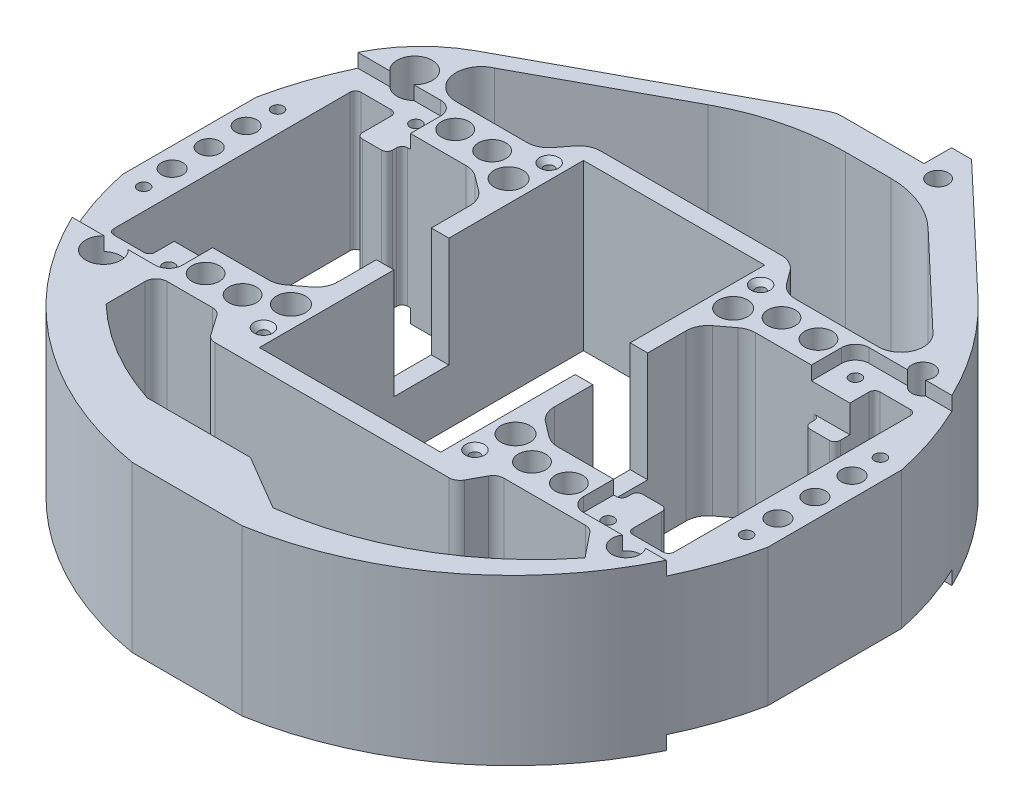
from build123d import *

# Parameters (mm, degrees)
SKETCH1_R             = 2.356484411
SKETCH1_R_2           = 3.356538595
SKETCH1_R_3           = 3.175
SKETCH1_R_4           = 4.064709562
SKETCH1_R_5           = 2.555437721
SKETCH1_R_6           = 3.242334338
SKETCH1_R_7           = 2.462755239
BOSS_EXTRUDE1_DEPTH   = 38.1
SKETCH2_W             = 4.064
SKETCH2_H             = 12.7
CUT_EXTRUDE1_DEPTH    = 25.4
CUT_EXTRUDE2_DEPTH    = 3.175
SKETCH4_R             = 1.35255
CUT_EXTRUDE3_DEPTH    = 6.35
SKETCH5_W             = 15.815775359
SKETCH5_H             = 5.307603771
CUT_EXTRUDE4_DEPTH    = 6.35
SKETCH6_R             = 1.1303
CUT_EXTRUDE5_DEPTH    = 12.7
CHAMFER1_SIZE         = 1.19507
CHAMFER1_SIZE2        = 1.038858502
CHAMFER2_SIZE         = 1.19507
CHAMFER2_SIZE2        = 1.038858502
CHAMFER2_PART_2_SIZE  = 1.19507
CHAMFER2_PART_2_SIZE2 = 1.038858502
CHAMFER2_PART_3_SIZE  = 1.19507
CHAMFER2_PART_3_SIZE2 = 1.038858502
CHAMFER2_PART_4_SIZE  = 1.19507
CHAMFER2_PART_4_SIZE2 = 1.038858502
SKETCH7_W             = 19.05
SKETCH7_H             = 15.875
CUT_EXTRUDE6_DEPTH    = 0.79375


with BuildPart() as part:
    # Sketch1 → Boss-Extrude1 (new body)
    with BuildSketch(Plane(origin=(0, 0, 0), x_dir=(1, 0, 0), z_dir=(0, 1, 0))):
        with BuildLine():
            Line((-74.6125, 15.473036022), (-74.6125, -15.473036022))
            ThreePointArc((-74.6125, -15.473036022), (-52.874683743, -54.86991725), (-12.7, -75.134213245))
            Line((-12.7, -75.134213245), (12.7, -75.134213245))
            ThreePointArc((12.7, -75.134213245), (52.874683743, -54.86991725), (74.6125, -15.473036022))
            Line((74.6125, -15.473036022), (74.6125, 15.473036022))
            ThreePointArc((74.6125, 15.473036022), (66.568680107, 37.081677804), (52.429845716, 55.295128883))
            Line((52.429845716, 55.295128883), (23.6855, 82.55))
            Line((23.6855, 82.55), (19.05, 82.55))
            Line((19.05, 82.55), (19.05, 76.99375))
            Line((19.05, 76.99375), (0, 76.99375))
            Line((0, 76.99375), (0, 76.2))
            ThreePointArc((0, 76.2), (-1.309576606, 76.036760248), (-2.539006662, 75.557031324))
            Line((-2.539006662, 75.557031324), (-55.150410299, 47.084918442))
            ThreePointArc((-55.150410299, 47.084918442), (-63.168001103, 40.936392006), (-68.874977996, 32.598733198))
            ThreePointArc((-68.874977996, 32.598733198), (-72.252933929, 24.206477205), (-74.6125, 15.473036022))
        make_face()
        with Locations((23.6855, 74.812542953)):
            Circle(SKETCH1_R, mode=Mode.SUBTRACT)
        with Locations((-25.953983408, 25.159074147)):
            Circle(SKETCH1_R_2, mode=Mode.SUBTRACT)
        with Locations((-41.987680119, 28.850105121)):
            Circle(SKETCH1_R_3, mode=Mode.SUBTRACT)
        with Locations((41.987680119, 28.850105121)):
            Circle(SKETCH1_R_3, mode=Mode.SUBTRACT)
        with Locations((-41.987680119, -28.850105121)):
            Circle(SKETCH1_R_3, mode=Mode.SUBTRACT)
        with Locations((41.987680119, -28.850105121)):
            Circle(SKETCH1_R_3, mode=Mode.SUBTRACT)
        with Locations((-33.451838253, 28.850105121)):
            Circle(SKETCH1_R_3, mode=Mode.SUBTRACT)
        with Locations((33.451838253, 28.850105121)):
            Circle(SKETCH1_R_3, mode=Mode.SUBTRACT)
        with Locations((-33.451838253, -28.850105121)):
            Circle(SKETCH1_R_3, mode=Mode.SUBTRACT)
        with Locations((33.451838253, -28.850105121)):
            Circle(SKETCH1_R_3, mode=Mode.SUBTRACT)
        with Locations((-58.499626731, 35.97459363)):
            Circle(SKETCH1_R_4, mode=Mode.SUBTRACT)
        with Locations((60.460006294, 34.52310187)):
            Circle(SKETCH1_R_5, mode=Mode.SUBTRACT)
        with Locations((-58.499626731, -35.97459363)):
            Circle(SKETCH1_R_4, mode=Mode.SUBTRACT)
        with Locations((61.236723994, -34.882223147)):
            Circle(SKETCH1_R_6, mode=Mode.SUBTRACT)
        with Locations((25.953983408, 25.159074147)):
            Circle(SKETCH1_R_2, mode=Mode.SUBTRACT)
        with Locations((25.953983408, -25.159074147)):
            Circle(SKETCH1_R_2, mode=Mode.SUBTRACT)
        with Locations((-25.953983408, -25.159074147)):
            Circle(SKETCH1_R_2, mode=Mode.SUBTRACT)
        with Locations((70.02564652, 8.562540674)):
            Circle(SKETCH1_R_7, mode=Mode.SUBTRACT)
        with Locations((-70.02564652, 8.562540674)):
            Circle(SKETCH1_R_7, mode=Mode.SUBTRACT)
        with Locations((70.02564652, -8.562540674)):
            Circle(SKETCH1_R_7, mode=Mode.SUBTRACT)
        with Locations((-70.02564652, -8.562540674)):
            Circle(SKETCH1_R_7, mode=Mode.SUBTRACT)
        with Locations((-70.02564652, 0)):
            Circle(SKETCH1_R_7, mode=Mode.SUBTRACT)
        with Locations((70.02564652, 0)):
            Circle(SKETCH1_R_7, mode=Mode.SUBTRACT)
        Polygon((20.955, 37.465), (-20.955, 37.465), (-20.955, 0), (-20.955, -37.465), (20.955, -37.465), (20.955, 0), align=None, mode=Mode.SUBTRACT)
        with BuildLine():
            Line((-53.975, 19.3675), (-49.53, 19.3675))
            ThreePointArc((-49.53, 19.3675), (-48.631974388, 19.739474388), (-48.26, 20.6375))
            Line((-48.26, 20.6375), (-48.26, 21.59))
            ThreePointArc((-48.26, 21.59), (-47.888025612, 22.488025612), (-46.99, 22.86))
            Line((-46.99, 22.86), (-33.451838253, 22.86))
            ThreePointArc((-33.451838253, 22.86), (-31.838145049, 22.596886364), (-30.391611171, 21.834800884))
            Line((-30.391611171, 21.834800884), (-27.038772918, 19.304356919))
            ThreePointArc((-27.038772918, 19.304356919), (-25.551893581, 17.514555641), (-25.019, 15.249556036))
            Line((-25.019, 15.249556036), (-25.019, 0))
            Line((-25.019, 0), (-25.019, -15.249556036))
            ThreePointArc((-25.019, -15.249556036), (-25.551893581, -17.514555641), (-27.038772918, -19.304356919))
            Line((-27.038772918, -19.304356919), (-30.391611171, -21.834800884))
            ThreePointArc((-30.391611171, -21.834800884), (-31.838145049, -22.596886364), (-33.451838253, -22.86))
            Line((-33.451838253, -22.86), (-46.99, -22.86))
            ThreePointArc((-46.99, -22.86), (-47.888025612, -22.488025612), (-48.26, -21.59))
            Line((-48.26, -21.59), (-48.26, -20.6375))
            ThreePointArc((-48.26, -20.6375), (-48.631974388, -19.739474388), (-49.53, -19.3675))
            Line((-49.53, -19.3675), (-53.975, -19.3675))
            ThreePointArc((-53.975, -19.3675), (-54.873025612, -19.739474388), (-55.245, -20.6375))
            Line((-55.245, -20.6375), (-55.245, -27.305))
            ThreePointArc((-55.245, -27.305), (-55.616974388, -28.203025612), (-56.515, -28.575))
            Line((-56.515, -28.575), (-63.5, -28.575))
            ThreePointArc((-63.5, -28.575), (-64.398025612, -28.203025612), (-64.77, -27.305))
            Line((-64.77, -27.305), (-64.77, 27.305))
            ThreePointArc((-64.77, 27.305), (-64.398025612, 28.203025612), (-63.5, 28.575))
            Line((-63.5, 28.575), (-56.515, 28.575))
            ThreePointArc((-56.515, 28.575), (-55.616974388, 28.203025612), (-55.245, 27.305))
            Line((-55.245, 27.305), (-55.245, 20.6375))
            ThreePointArc((-55.245, 20.6375), (-54.873025612, 19.739474388), (-53.975, 19.3675))
        make_face(mode=Mode.SUBTRACT)
        with BuildLine():
            Line((64.77, 27.305), (64.77, -27.305))
            ThreePointArc((64.77, -27.305), (64.398025612, -28.203025612), (63.5, -28.575))
            Line((63.5, -28.575), (56.515, -28.575))
            ThreePointArc((56.515, -28.575), (55.616974388, -28.203025612), (55.245, -27.305))
            Line((55.245, -27.305), (55.245, -20.6375))
            ThreePointArc((55.245, -20.6375), (54.873025612, -19.739474388), (53.975, -19.3675))
            Line((53.975, -19.3675), (49.53, -19.3675))
            ThreePointArc((49.53, -19.3675), (48.631974388, -19.739474388), (48.26, -20.6375))
            Line((48.26, -20.6375), (48.26, -21.59))
            ThreePointArc((48.26, -21.59), (47.888025612, -22.488025612), (46.99, -22.86))
            Line((46.99, -22.86), (33.451838253, -22.86))
            ThreePointArc((33.451838253, -22.86), (31.838145049, -22.596886364), (30.391611171, -21.834800884))
            Line((30.391611171, -21.834800884), (27.038772918, -19.304356919))
            ThreePointArc((27.038772918, -19.304356919), (25.551893581, -17.514555641), (25.019, -15.249556036))
            Line((25.019, -15.249556036), (25.019, 0))
            Line((25.019, 0), (25.019, 15.249556036))
            ThreePointArc((25.019, 15.249556036), (25.551893581, 17.514555641), (27.038772918, 19.304356919))
            Line((27.038772918, 19.304356919), (30.391611171, 21.834800884))
            ThreePointArc((30.391611171, 21.834800884), (31.838145049, 22.596886364), (33.451838253, 22.86))
            Line((33.451838253, 22.86), (46.99, 22.86))
            ThreePointArc((46.99, 22.86), (47.888025612, 22.488025612), (48.26, 21.59))
            Line((48.26, 21.59), (48.26, 20.6375))
            ThreePointArc((48.26, 20.6375), (48.631974388, 19.739474388), (49.53, 19.3675))
            Line((49.53, 19.3675), (53.975, 19.3675))
            ThreePointArc((53.975, 19.3675), (54.873025612, 19.739474388), (55.245, 20.6375))
            Line((55.245, 20.6375), (55.245, 27.305))
            ThreePointArc((55.245, 27.305), (55.616974388, 28.203025612), (56.515, 28.575))
            Line((56.515, 28.575), (63.5, 28.575))
            ThreePointArc((63.5, 28.575), (64.398025612, 28.203025612), (64.77, 27.305))
        make_face(mode=Mode.SUBTRACT)
        with BuildLine():
            Line((-20.845950883, 41.338131188), (0, 41.338131188))
            Line((0, 41.338131188), (20.910135118, 41.338131188))
            ThreePointArc((20.910135118, 41.338131188), (23.203410667, 40.791042753), (25.00273955, 39.267614359))
            Line((25.00273955, 39.267614359), (27.190928166, 36.29189065))
            ThreePointArc((27.190928166, 36.29189065), (28.990257049, 34.768462257), (31.283532598, 34.221373822))
            Line((31.283532598, 34.221373822), (50.455815119, 34.221373822))
            ThreePointArc((50.455815119, 34.221373822), (55.316788611, 37.516325014), (54.056495, 43.251952848))
            Line((54.056495, 43.251952848), (32.476102374, 63.71409262))
            ThreePointArc((32.476102374, 63.71409262), (25.857925946, 67.947781019), (18.142380695, 69.429245892))
            Line((18.142380695, 69.429245892), (7.650592912, 69.429245892))
            ThreePointArc((7.650592912, 69.429245892), (-5.443696115, 67.79703249), (-17.736610037, 63.000284321))
            Line((-17.736610037, 63.000284321), (-49.707341043, 45.69844101))
            ThreePointArc((-49.707341043, 45.69844101), (-53.151906064, 39.187793332), (-47.451536346, 34.52310187))
            Line((-47.451536346, 34.52310187), (-31.086999544, 34.52310187))
            ThreePointArc((-31.086999544, 34.52310187), (-28.840846685, 35.046656179), (-27.057679262, 36.509402133))
            Line((-27.057679262, 36.509402133), (-24.875271165, 39.351830925))
            ThreePointArc((-24.875271165, 39.351830925), (-23.092103742, 40.814576878), (-20.845950883, 41.338131188))
        make_face(mode=Mode.SUBTRACT)
        with BuildLine():
            Line((-23.854336738, -60.495536567), (0, -60.495536567))
            Line((0, -60.495536567), (12.7, -67.96894498))
            ThreePointArc((12.7, -67.96894498), (38.322472705, -59.497281046), (58.80689112, -41.928308409))
            Line((58.80689112, -41.928308409), (54.275996481, -36.293661738))
            ThreePointArc((54.275996481, -36.293661738), (53.394000982, -35.594661364), (52.296567671, -35.345346879))
            Line((52.296567671, -35.345346879), (33.457769344, -35.345346879))
            ThreePointArc((33.457769344, -35.345346879), (32.159314658, -35.702317921), (31.225829045, -36.672893786))
            Line((31.225829045, -36.672893786), (29.270713217, -40.271962344))
            ThreePointArc((29.270713217, -40.271962344), (28.337227604, -41.242538208), (27.038772918, -41.599509251))
            Line((27.038772918, -41.599509251), (-27.038772918, -41.599509251))
            ThreePointArc((-27.038772918, -41.599509251), (-28.216614381, -41.30990688), (-29.125868694, -40.507138769))
            Line((-29.125868694, -40.507138769), (-32.269685191, -35.97459363))
            ThreePointArc((-32.269685191, -35.97459363), (-33.178939505, -35.171825519), (-34.356780968, -34.882223147))
            Line((-34.356780968, -34.882223147), (-44.859278162, -34.882223147))
            ThreePointArc((-44.859278162, -34.882223147), (-46.655329386, -35.626171923), (-47.399278162, -37.422223147))
            Line((-47.399278162, -37.422223147), (-47.399278162, -46.454771748))
            ThreePointArc((-47.399278162, -46.454771748), (-36.419314032, -54.804107481), (-23.854336738, -60.495536567))
        make_face(mode=Mode.SUBTRACT)
    extrude(amount=BOSS_EXTRUDE1_DEPTH)

    # Sketch2 → Cut-Extrude1 (cut)
    with BuildSketch(Plane(origin=(0, 38.1, 0), x_dir=(1, 0, 0), z_dir=(0, 1, 0))):
        with Locations((-22.987, 0)):
            Rectangle(SKETCH2_W, SKETCH2_H)
        with Locations((22.987, 0)):
            Rectangle(SKETCH2_W, SKETCH2_H)
    extrude(amount=-CUT_EXTRUDE1_DEPTH, mode=Mode.SUBTRACT)

    # Sketch3 → Cut-Extrude2 (cut)
    with BuildSketch(Plane(origin=(0, 38.1, 0), x_dir=(1, 0, 0), z_dir=(0, 1, 0))):
        with BuildLine():
            Line((-49.53, 33.02), (-80.011418761, 33.02))
            Line((-80.011418761, 33.02), (-80.011418761, -33.02))
            Line((-80.011418761, -33.02), (-49.53, -33.02))
            ThreePointArc((-49.53, -33.02), (-47.28493597, -32.09006403), (-46.355, -29.845))
            Line((-46.355, -29.845), (-46.355, 29.845))
            ThreePointArc((-46.355, 29.845), (-47.28493597, 32.09006403), (-49.53, 33.02))
        make_face()
        with BuildLine():
            Line((80.011418761, 33.02), (80.011418761, -33.02))
            Line((80.011418761, -33.02), (49.53, -33.02))
            ThreePointArc((49.53, -33.02), (47.28493597, -32.09006403), (46.355, -29.845))
            Line((46.355, -29.845), (46.355, 29.845))
            ThreePointArc((46.355, 29.845), (47.28493597, 32.09006403), (49.53, 33.02))
            Line((49.53, 33.02), (80.011418761, 33.02))
        make_face()
    cut_extrude2 = extrude(amount=-CUT_EXTRUDE2_DEPTH, mode=Mode.SUBTRACT)

    # Sketch4 → Cut-Extrude3 (cut)
    with BuildSketch(Plane(origin=(0, 34.925, 0), x_dir=(1, 0, 0), z_dir=(0, 1, 0))):
        with Locations((-50.8, 28.575)):
            Circle(SKETCH4_R)
        with Locations((-69.69125, 15.473036022)):
            Circle(SKETCH4_R)
        with Locations((69.69125, 15.473036022)):
            Circle(SKETCH4_R)
        with Locations((50.8, 28.575)):
            Circle(SKETCH4_R)
        with Locations((50.8, -28.575)):
            Circle(SKETCH4_R)
        with Locations((69.69125, -15.473036022)):
            Circle(SKETCH4_R)
        with Locations((-69.69125, -15.473036022)):
            Circle(SKETCH4_R)
        with Locations((-50.8, -28.575)):
            Circle(SKETCH4_R)
    cut_extrude3 = extrude(amount=-CUT_EXTRUDE3_DEPTH, mode=Mode.SUBTRACT)

    # Mirror1: Cut-Extrude2, Cut-Extrude3 across plane
    add(cut_extrude2.mirror(Plane.ZX.offset(19.05)), mode=Mode.SUBTRACT)
    add(cut_extrude3.mirror(Plane.ZX.offset(19.05)), mode=Mode.SUBTRACT)

    # Sketch5 → Cut-Extrude4 (cut)
    with BuildSketch(Plane(origin=(0, 34.925, 0), x_dir=(1, 0, 0), z_dir=(0, 1, 0))):
        with Locations((-49.473916364, -20.206198115)):
            Rectangle(SKETCH5_W, SKETCH5_H)
        with Locations((49.473916364, 20.206198115)):
            Rectangle(SKETCH5_W, SKETCH5_H)
    extrude(amount=-CUT_EXTRUDE4_DEPTH, mode=Mode.SUBTRACT)

    # Sketch6 → Cut-Extrude5 (cut)
    with BuildSketch(Plane.XZ):
        with Locations((-24.4475, 33.02)):
            Circle(SKETCH6_R)
        with Locations((24.4475, 33.02)):
            Circle(SKETCH6_R)
        with Locations((24.4475, -33.02)):
            Circle(SKETCH6_R)
        with Locations((-24.4475, -33.02)):
            Circle(SKETCH6_R)
    cut_extrude5 = extrude(amount=-CUT_EXTRUDE5_DEPTH, mode=Mode.SUBTRACT)

    # Chamfer1
    chamfer1_edges = [part.edges().sort_by_distance(p)[0] for p in [
        (-25.5778, 0, 33.02),
        (23.3172, 0, 33.02),
        (23.3172, 0, -33.02),
        (-25.5778, 0, -33.02),
    ]]
    chamfer1_side = [part.faces().sort_by_distance(p)[0] for p in [
        (-61.499047854, 0, -39.656316186),
    ]]
    chamfer(chamfer1_edges, length=CHAMFER1_SIZE, length2=CHAMFER1_SIZE2, reference=chamfer1_side[0])

    # Mirror9: Cut-Extrude5 across plane
    add(cut_extrude5.mirror(Plane.ZX.offset(19.05)), mode=Mode.SUBTRACT)

    # Chamfer2
    chamfer2_edges = [part.edges().sort_by_distance(p)[0] for p in [
        (-25.5778, 38.1, 33.02),
    ]]
    chamfer2_side = [part.faces().sort_by_distance(p)[0] for p in [
        (-25.5778, 31.75, 33.02),
    ]]
    chamfer(chamfer2_edges, length=CHAMFER2_SIZE, length2=CHAMFER2_SIZE2, reference=chamfer2_side[0])

    # Chamfer2 part 2
    chamfer2_part_2_edges = [part.edges().sort_by_distance(p)[0] for p in [
        (23.3172, 38.1, 33.02),
    ]]
    chamfer2_part_2_side = [part.faces().sort_by_distance(p)[0] for p in [
        (23.3172, 31.75, 33.02),
    ]]
    chamfer(chamfer2_part_2_edges, length=CHAMFER2_PART_2_SIZE, length2=CHAMFER2_PART_2_SIZE2, reference=chamfer2_part_2_side[0])

    # Chamfer2 part 3
    chamfer2_part_3_edges = [part.edges().sort_by_distance(p)[0] for p in [
        (23.3172, 38.1, -33.02),
    ]]
    chamfer2_part_3_side = [part.faces().sort_by_distance(p)[0] for p in [
        (23.3172, 31.75, -33.02),
    ]]
    chamfer(chamfer2_part_3_edges, length=CHAMFER2_PART_3_SIZE, length2=CHAMFER2_PART_3_SIZE2, reference=chamfer2_part_3_side[0])

    # Chamfer2 part 4
    chamfer2_part_4_edges = [part.edges().sort_by_distance(p)[0] for p in [
        (-25.5778, 38.1, -33.02),
    ]]
    chamfer2_part_4_side = [part.faces().sort_by_distance(p)[0] for p in [
        (-25.5778, 31.75, -33.02),
    ]]
    chamfer(chamfer2_part_4_edges, length=CHAMFER2_PART_4_SIZE, length2=CHAMFER2_PART_4_SIZE2, reference=chamfer2_part_4_side[0])

    # Sketch7 → Cut-Extrude6 (cut)
    with BuildSketch(Plane(origin=(0, 0, -76.99375), x_dir=(-1, 0, 0), z_dir=(0, 0, -1))):
        with Locations((-9.525, 7.9375)):
            Rectangle(SKETCH7_W, SKETCH7_H)
        with Locations((-9.525, 30.1625)):
            Rectangle(SKETCH7_W, SKETCH7_H)
    extrude(amount=-CUT_EXTRUDE6_DEPTH, mode=Mode.SUBTRACT)


solid = part.part
